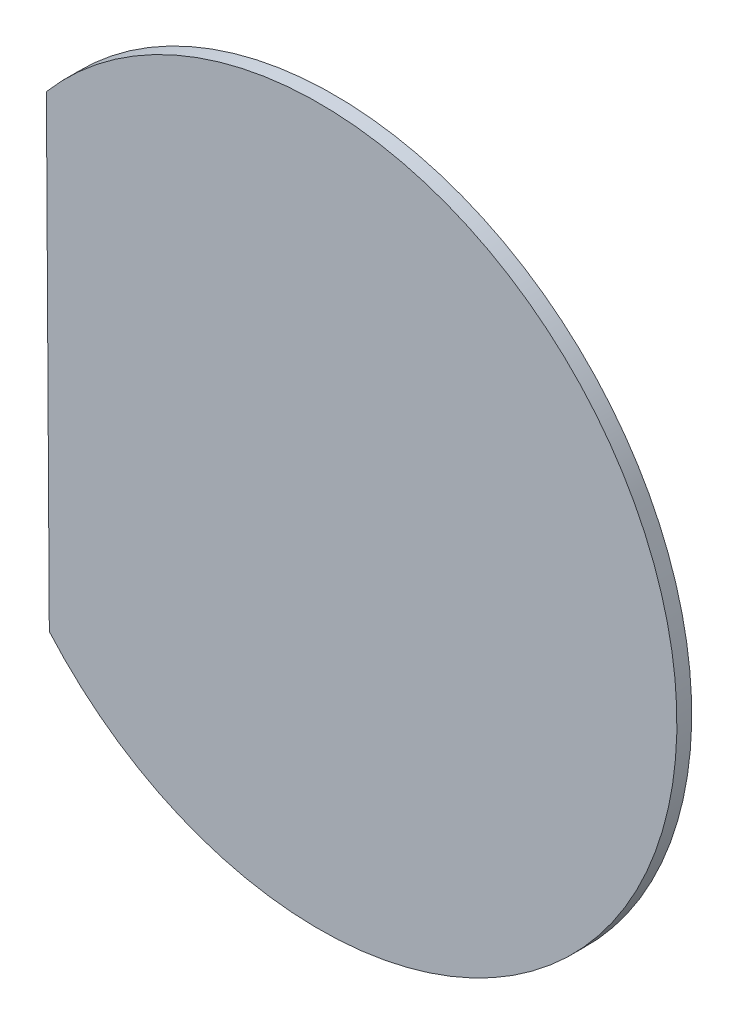
from build123d import *

# Parameters (mm, degrees)
BOSS_EXTRU_1_DEPTH = 6


with BuildPart() as part:
    # Esquisse1 → Boss.-Extru.1 (new body)
    with BuildSketch(Plane.XY):
        with BuildLine():
            ThreePointArc((145, 0), (49.947727788, 136.125767174), (-110.589303294, 93.781693294))
            Line((-110.589303294, 93.781693294), (-109.40638511, -95.159040018))
            ThreePointArc((-109.40638511, -95.159040018), (50.798986993, -135.810393271), (145, 0))
        make_face()
    extrude(amount=BOSS_EXTRU_1_DEPTH)


solid = part.part
